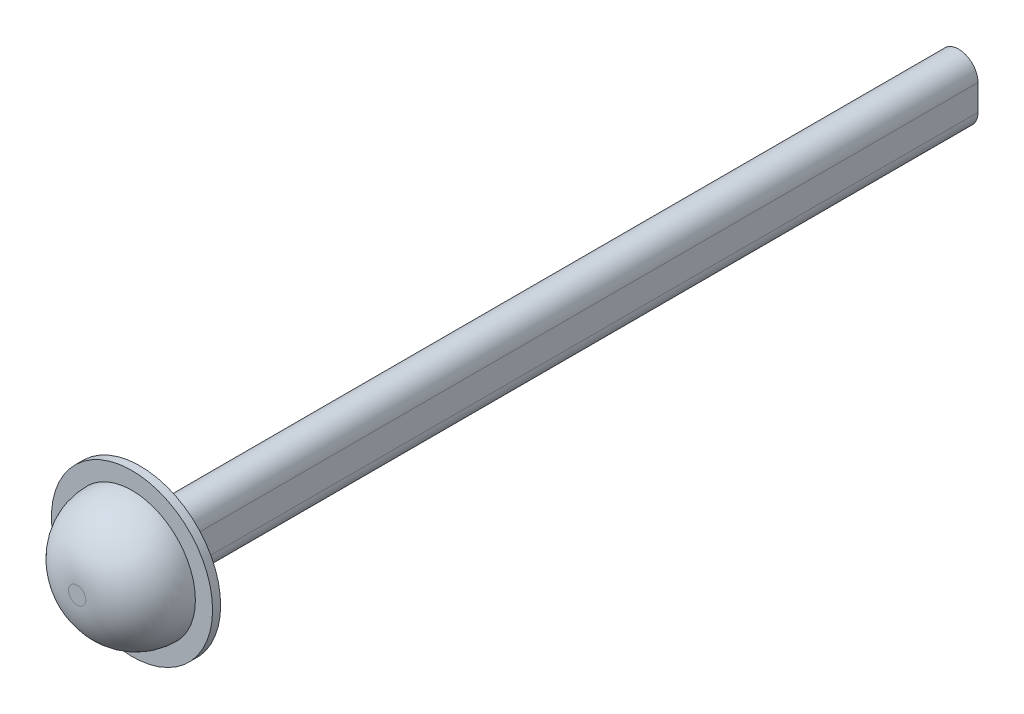
from build123d import *

# Parameters (mm, degrees)
EXTRUDE_1_DEPTH = 254
SKETCH_3_R      = 25
EXTRUDE_2_DEPTH = 2.5
CHAMFER_1_SIZE  = 3


with BuildPart() as part:
    # 草图2 → 凸台-拉伸1 (new body)
    with BuildSketch(Plane.XY):
        with BuildLine():
            Line((6, 4), (6, -4))
            ThreePointArc((6, -4), (0, -10), (-6, -4))
            Line((-6, -4), (-6, 4))
            ThreePointArc((-6, 4), (0, 10), (6, 4))
        make_face()
    extrude(amount=EXTRUDE_1_DEPTH)

    # 草图3 → 凸台-拉伸2 (add)
    with BuildSketch(Plane.XY.offset(254)):
        Circle(SKETCH_3_R)
    extrude(amount=EXTRUDE_2_DEPTH)

    # 倒角1
    chamfer_1_edges = [part.edges().sort_by_distance(p)[0] for p in [
        (0, -10, 254),
        (6, 0, 254),
        (0, 10, 254),
        (-6, 0, 254),
    ]]
    chamfer(chamfer_1_edges, length=CHAMFER_1_SIZE)

    # 草图4 → 旋转1 (revolve)
    with BuildSketch(Plane(origin=(0, 0, 0), x_dir=(0, 0, -1), z_dir=(1, 0, 0))):
        with BuildLine():
            Line((-256.5, 0), (-256.5, -19.669640386))
            ThreePointArc((-256.5, -19.669640386), (-268.52081528, -14.690455667), (-273.5, -2.669640386))
            Line((-273.5, -2.669640386), (-273.5, 0))
            Line((-273.5, 0), (-256.5, 0))
        make_face()
    revolve(axis=Axis((0, 0, 273.5), (0, 0, -1)))


solid = part.part
